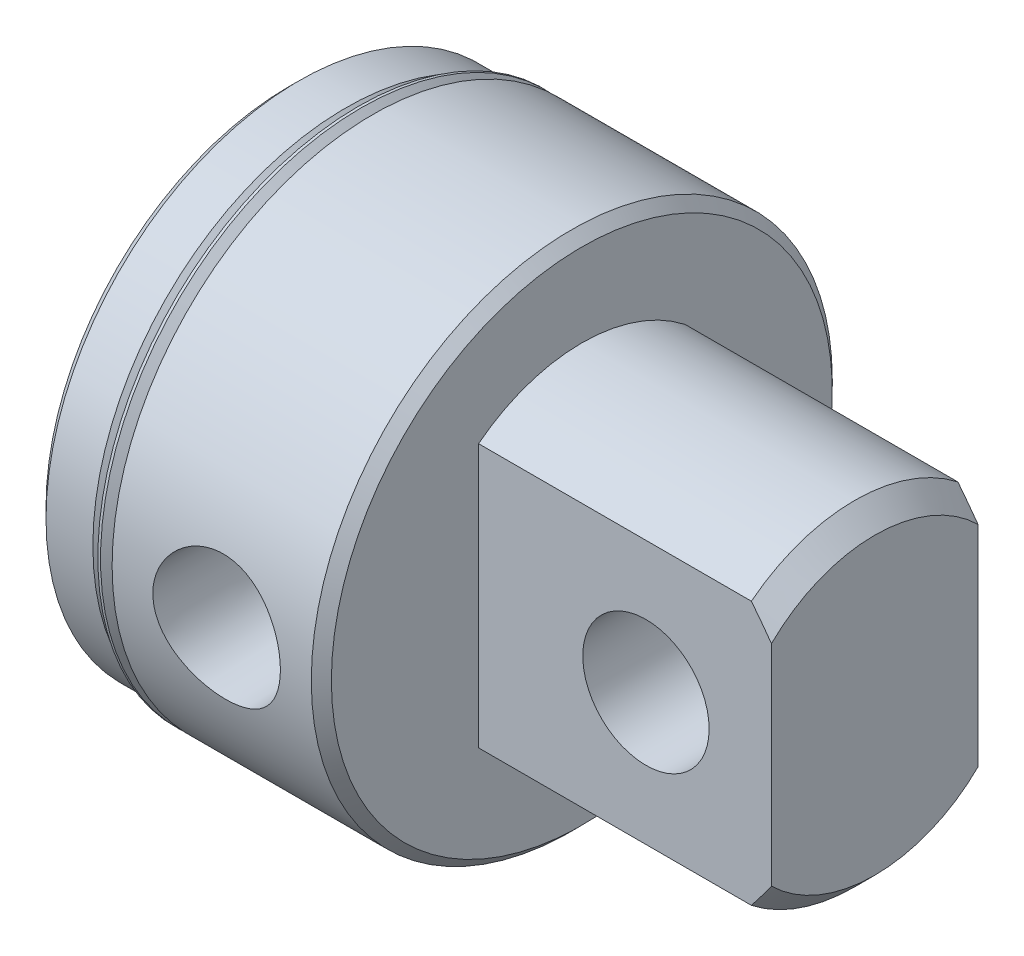
from build123d import *

# Parameters (mm, degrees)
SKETCH3_W               = 79.0702
SKETCH3_H               = 158.1404
SKETCH3_W_2             = 15.6718
SKETCH3_H_2             = 79.0702
CUT_EXTRUDE1_DEPTH      = 22.225
HOLE1_D                 = 13.5128
HOLE1_DEPTH             = 20.45208
HOLE1_TIP               = 3.900809359
SKETCH7_W               = 6.35
SKETCH7_H               = 12.3063
CUT_EXTRUDE2_DEPTH      = 11.75385
CUT_EXTRUDE2_DEPTH_BACK = 11.75385
SKETCH9_R               = 4.79425


with BuildPart() as part:
    # Sketch1 → Revolve1 (revolve)
    with BuildSketch(Plane.XY):
        Polygon((0, 0), (0, 18.43405), (0.762, 19.19605), (4.318, 19.19605), (5.334, 18.18005), (6.35, 18.18005), (6.35, 19.76755), (21.463, 19.76755), (22.225, 19.00555), (22.225, 0), align=None)
    revolve(axis=Axis((22.225, 0, 0), (-1, 0, 0)))

    # Sketch2 → Revolve2 (revolve)
    with BuildSketch(Plane.XY):
        Polygon((22.225, 0), (22.225, 12.7), (42.926, 12.7), (44.45, 11.176), (44.45, 0), align=None)
    revolve(axis=Axis((44.45, 0, 0), (-1, 0, 0)))

    # Sketch3 → Cut-Extrude1 (cut)
    with BuildSketch(Plane(origin=(44.45, 0, 0), x_dir=(0, 0, -1), z_dir=(1, 0, 0))):
        Rectangle(SKETCH3_W, SKETCH3_H)
        Rectangle(SKETCH3_W_2, SKETCH3_H_2, mode=Mode.SUBTRACT)
    extrude(amount=-CUT_EXTRUDE1_DEPTH, mode=Mode.SUBTRACT)

    # Hole1
    with Locations(Plane.ZY):
        with Locations((0, 0)):
            Hole(HOLE1_D / 2, depth=HOLE1_DEPTH)
            with Locations((0, 0, -(HOLE1_DEPTH + HOLE1_TIP / 2))):  # 120° drill point
                Cone(0, HOLE1_D / 2, HOLE1_TIP, mode=Mode.SUBTRACT)

    # Sketch6 → Cut-Revolve1 (revolve, cut)
    with BuildSketch(Plane(origin=(0, 0, 0), x_dir=(1, 0, 0), z_dir=(0, 0.9998476951563913, 0.01745240643728403))):
        Polygon((14.2748, 0), (18.897793378, 0), (18.897793378, -12.83335), (19.114275925, -19.76755), (14.2748, -19.76755), align=None)
    revolve(axis=Axis((14.2748, -0.344991317, 19.764539306), (0, 0.01745240643728403, -0.9998476951563913)), mode=Mode.SUBTRACT)

    # Sketch7 → Cut-Revolve2 (revolve, cut)
    with BuildSketch(Plane.XY):
        with Locations((3.175, 6.15315)):
            Rectangle(SKETCH7_W, SKETCH7_H)
    revolve(axis=Axis((6.35, 0, 0), (-1, 0, 0)), mode=Mode.SUBTRACT)

    # Sketch8 → Revolve3 (revolve)
    with BuildSketch(Plane.XY):
        with BuildLine():
            Line((5.267509175, 19.683381804), (6.216617928, 18.734273051))
            ThreePointArc((6.216617928, 18.734273051), (6.253815367, 18.64447049), (6.216617928, 18.554667928))
            Line((6.216617928, 18.554667928), (5.842, 18.18005))
            Line((5.842, 18.18005), (5.334, 18.18005))
            Line((5.334, 18.18005), (5.334, 17.92605))
            Line((5.334, 17.92605), (6.35, 17.92605))
            Line((6.35, 17.92605), (6.35, 18.888259175))
            Line((6.35, 18.888259175), (5.470709175, 19.76755))
            Line((5.470709175, 19.76755), (5.267509175, 19.76755))
            Line((5.267509175, 19.76755), (5.267509175, 19.683381804))
        make_face()
    revolve(axis=Axis((6.35, 0, 0), (-1, 0, 0)))

    # Sketch9 → Cut-Extrude2 (cut, two sides: drawn at the far end of the back side and taken through both)
    with BuildSketch(Plane.XY.offset(-CUT_EXTRUDE2_DEPTH_BACK)):
        with Locations((34.925, 0)):
            Circle(SKETCH9_R)
    extrude(amount=CUT_EXTRUDE2_DEPTH + CUT_EXTRUDE2_DEPTH_BACK, mode=Mode.SUBTRACT)


solid = part.part
